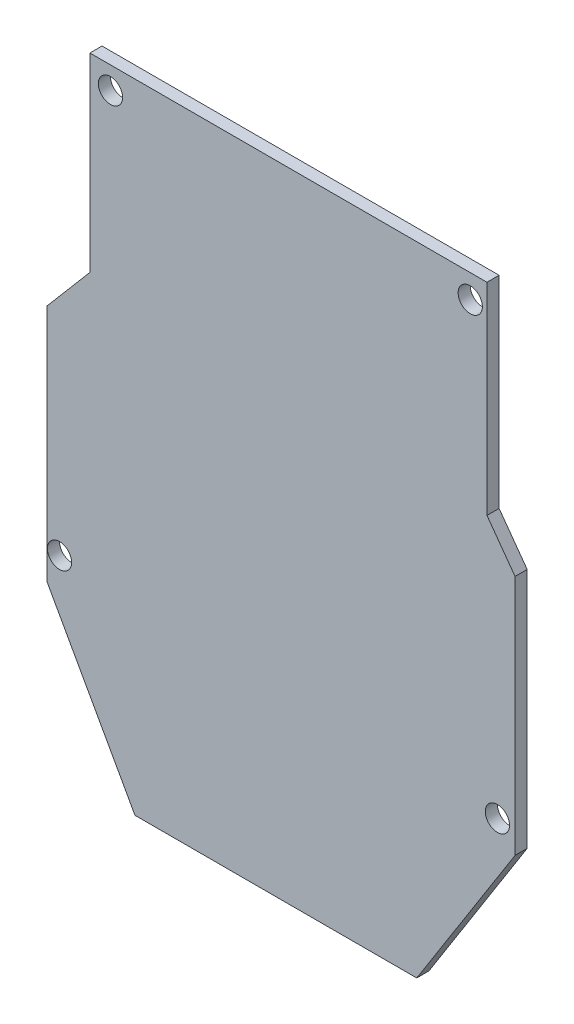
from build123d import *

# Parameters (mm, degrees)
SKETCH1_R           = 2
BOSS_EXTRUDE1_DEPTH = 2


with BuildPart() as part:
    # Sketch1 → Boss-Extrude1 (new body)
    with BuildSketch(Plane.XY):
        Polygon((-32.023386605, 16.542589641), (-24.91346955, 24.911431191), (-24.91346955, 56.269461149), (40.616772294, 56.269461149), (40.616772294, 22.944104941), (45.254370516, 16.542589641), (45.254370516, -23.335129549), (29.028050428, -48.968175245), (-17.475808115, -48.968175245), (-32.023386605, -22.782078707), align=None)
        with Locations((-21.522734493, 52.601108192)):
            Circle(SKETCH1_R, mode=Mode.SUBTRACT)
        with Locations((37.855643931, 52.388646343)):
            Circle(SKETCH1_R, mode=Mode.SUBTRACT)
        with Locations((42.340678938, -19.508435256)):
            Circle(SKETCH1_R, mode=Mode.SUBTRACT)
        with Locations((-29.92943, -18.063816679)):
            Circle(SKETCH1_R, mode=Mode.SUBTRACT)
    extrude(amount=BOSS_EXTRUDE1_DEPTH)


solid = part.part
